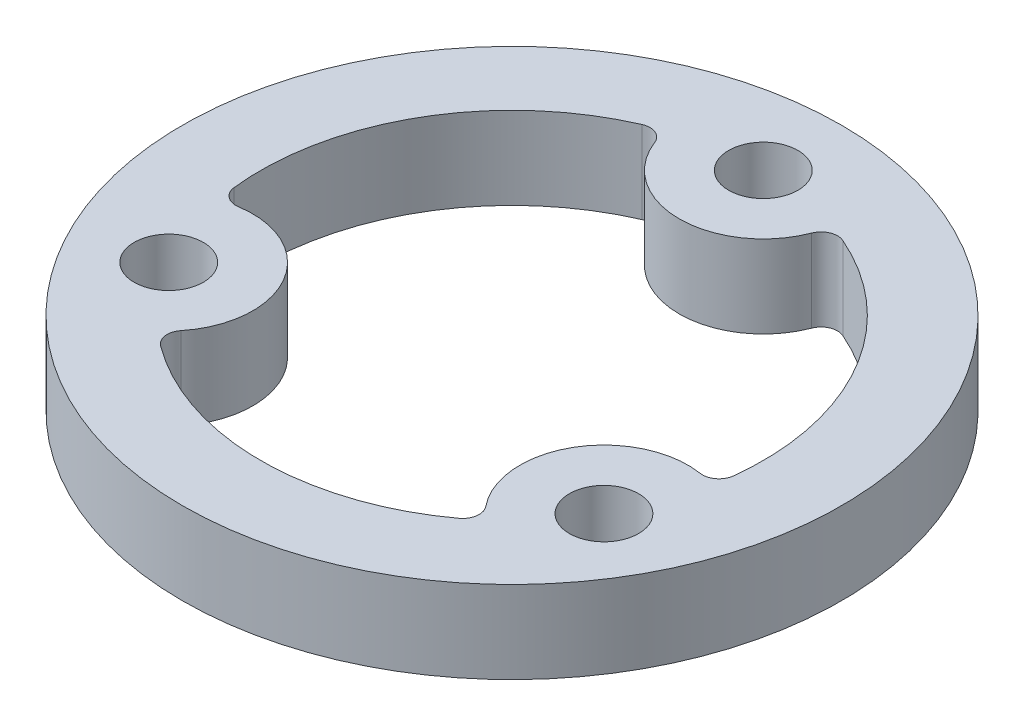
from build123d import *

# Parameters (mm, degrees)
SKETCH1_R           = 20
SKETCH1_R_2         = 10
SKETCH1_R_3         = 2.1
BOSS_EXTRUDE1_DEPTH = 5
CUT_EXTRUDE1_DEPTH  = 6
FILLET1_R           = 1


with BuildPart() as part:
    # Sketch1 → Boss-Extrude1 (new body)
    with BuildSketch(Plane(origin=(0, 0, 0), x_dir=(1, 0, 0), z_dir=(0, 1, 0))):
        Circle(SKETCH1_R)
        Circle(SKETCH1_R_2, mode=Mode.SUBTRACT)
        with Locations((0, 15.25)):
            Circle(SKETCH1_R_3, mode=Mode.SUBTRACT)
        with Locations((13.206887408, -7.625)):
            Circle(SKETCH1_R_3, mode=Mode.SUBTRACT)
        with Locations((-13.206887408, -7.625)):
            Circle(SKETCH1_R_3, mode=Mode.SUBTRACT)
    extrude(amount=BOSS_EXTRUDE1_DEPTH)

    # Sketch2 → Cut-Extrude1 (cut, through all)
    with BuildSketch(Plane(origin=(0, 5, 0), x_dir=(1, 0, 0), z_dir=(0, 1, 0))):
        with BuildLine():
            ThreePointArc((-5.028195952, 14.397213115), (0, 10.15), (5.028195952, 14.397213115))
            ThreePointArc((5.028195952, 14.397213115), (13.206887408, 7.625), (14.982450277, -2.844061128))
            ThreePointArc((14.982450277, -2.844061128), (8.790157848, -5.075), (9.954254325, -11.553151987))
            ThreePointArc((9.954254325, -11.553151987), (0, -15.25), (-9.954254325, -11.553151987))
            ThreePointArc((-9.954254325, -11.553151987), (-8.790157848, -5.075), (-14.982450277, -2.844061128))
            ThreePointArc((-14.982450277, -2.844061128), (-13.206887408, 7.625), (-5.028195952, 14.397213115))
        make_face()
    extrude(amount=-CUT_EXTRUDE1_DEPTH, mode=Mode.SUBTRACT)

    # Fillet1
    fillet1_edges = [part.edges().sort_by_distance(p)[0] for p in [
        (-14.982450277, 2.5, 2.844061128),
        (-5.028195952, 2.5, -14.397213115),
        (5.028195952, 2.5, -14.397213115),
        (14.982450277, 2.5, 2.844061128),
        (9.954254325, 2.5, 11.553151987),
        (-9.954254325, 2.5, 11.553151987),
    ]]
    fillet(fillet1_edges, radius=FILLET1_R)


solid = part.part
